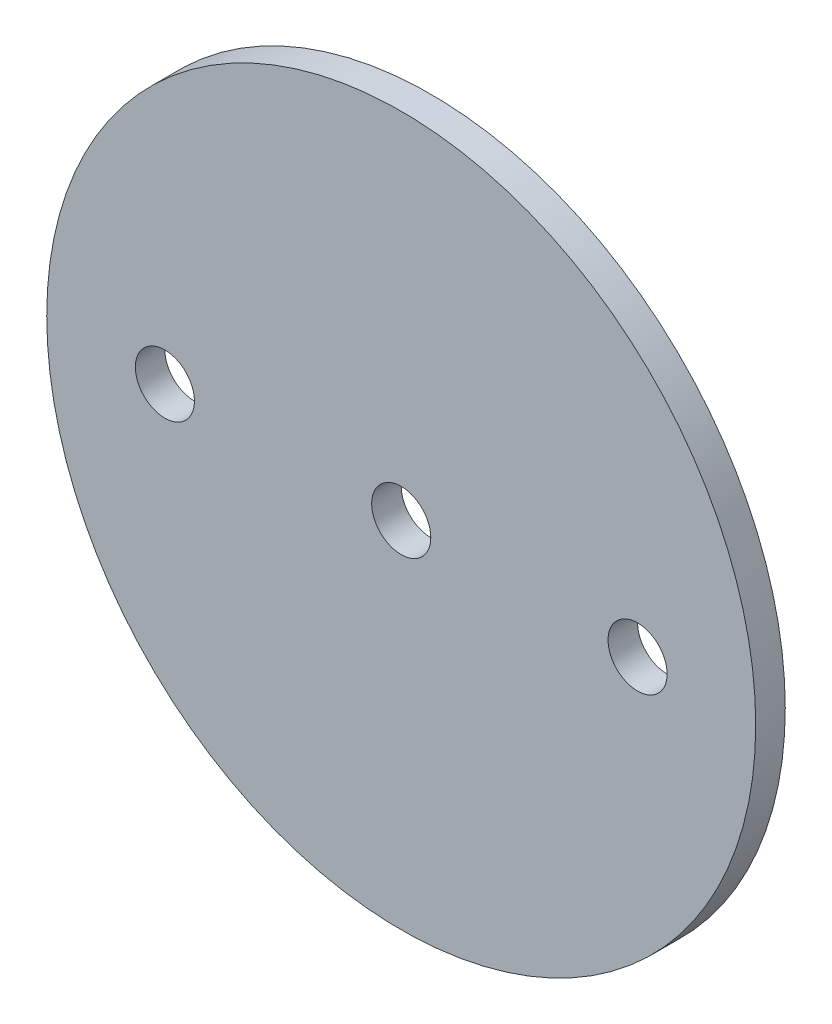
from build123d import *

# Parameters (mm, degrees)
SKETCH1_R                   = 38.1
BOSS_EXTRUDE1_DEPTH         = 1.5875
F_1_4_0_25_DIAMETER_HOLE1_D = 6.35


with BuildPart() as part:
    # Sketch1 → Boss-Extrude1 (new body, symmetric)
    with BuildSketch(Plane.XY):
        Circle(SKETCH1_R)
    extrude(amount=BOSS_EXTRUDE1_DEPTH, both=True)

    # 1/4 (0.25) Diameter Hole1 (through all)
    with Locations(Plane.XY.offset(1.5875)):
        with Locations((-25.4, 0), (0, 0), (25.4, 0)):
            Hole(F_1_4_0_25_DIAMETER_HOLE1_D / 2)


solid = part.part
